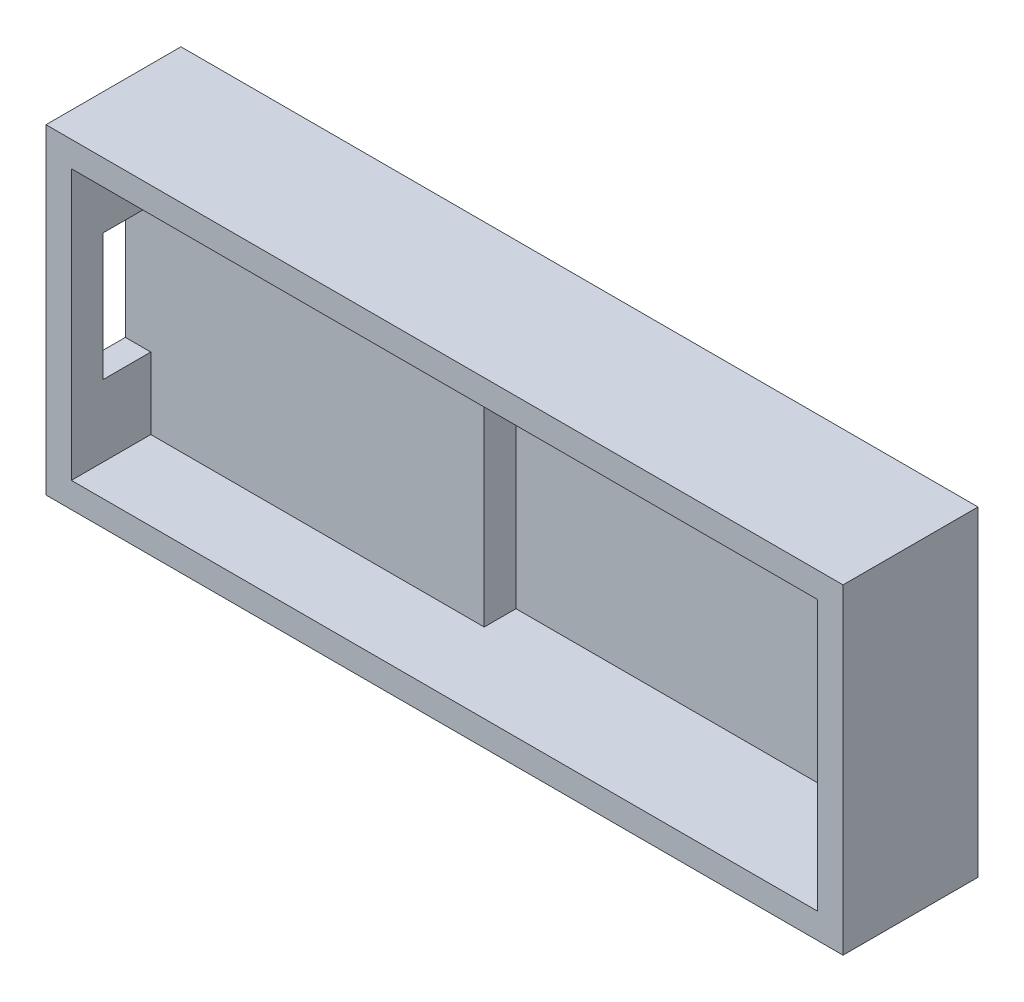
from build123d import *

# Parameters (mm, degrees)
SKETCH1_W           = 47
SKETCH1_H           = 17
BOSS_EXTRUDE1_DEPTH = 1.5
SKETCH3_W           = 21
SKETCH3_H           = 17
SKETCH3_W_2         = 4
SKETCH3_H_2         = 2
BOSS_EXTRUDE3_DEPTH = 2
SKETCH2_W           = 50.2
SKETCH2_H           = 20.2
SKETCH2_W_2         = 47
SKETCH2_H_2         = 17
BOSS_EXTRUDE2_DEPTH = 8.5
SKETCH4_W           = 3
SKETCH4_H           = 8
CUT_EXTRUDE1_DEPTH  = 2.6


with BuildPart() as part:
    # Sketch1 → Boss-Extrude1 (new body)
    with BuildSketch(Plane.XY):
        Rectangle(SKETCH1_W, SKETCH1_H)
    extrude(amount=BOSS_EXTRUDE1_DEPTH)

    # Sketch3 → Boss-Extrude3 (add)
    with BuildSketch(Plane.XY.offset(1.5)):
        with Locations((-13, 0)):
            Rectangle(SKETCH3_W, SKETCH3_H)
        with Locations((21.5, 7.5)):
            Rectangle(SKETCH3_W_2, SKETCH3_H_2)
        with Locations((21.5, -7.5)):
            Rectangle(SKETCH3_W_2, SKETCH3_H_2)
    extrude(amount=BOSS_EXTRUDE3_DEPTH)

    # Sketch2 → Boss-Extrude2 (add)
    with BuildSketch(Plane.XY):
        Rectangle(SKETCH2_W, SKETCH2_H)
        Rectangle(SKETCH2_W_2, SKETCH2_H_2, mode=Mode.SUBTRACT)
    extrude(amount=BOSS_EXTRUDE2_DEPTH)

    # Sketch4 → Cut-Extrude1 (cut, through all)
    with BuildSketch(Plane(origin=(-23.5, 0, 0), x_dir=(0, 0, -1), z_dir=(1, 0, 0))):
        with Locations((-5, 0)):
            Rectangle(SKETCH4_W, SKETCH4_H)
    extrude(amount=-CUT_EXTRUDE1_DEPTH, mode=Mode.SUBTRACT)


solid = part.part
